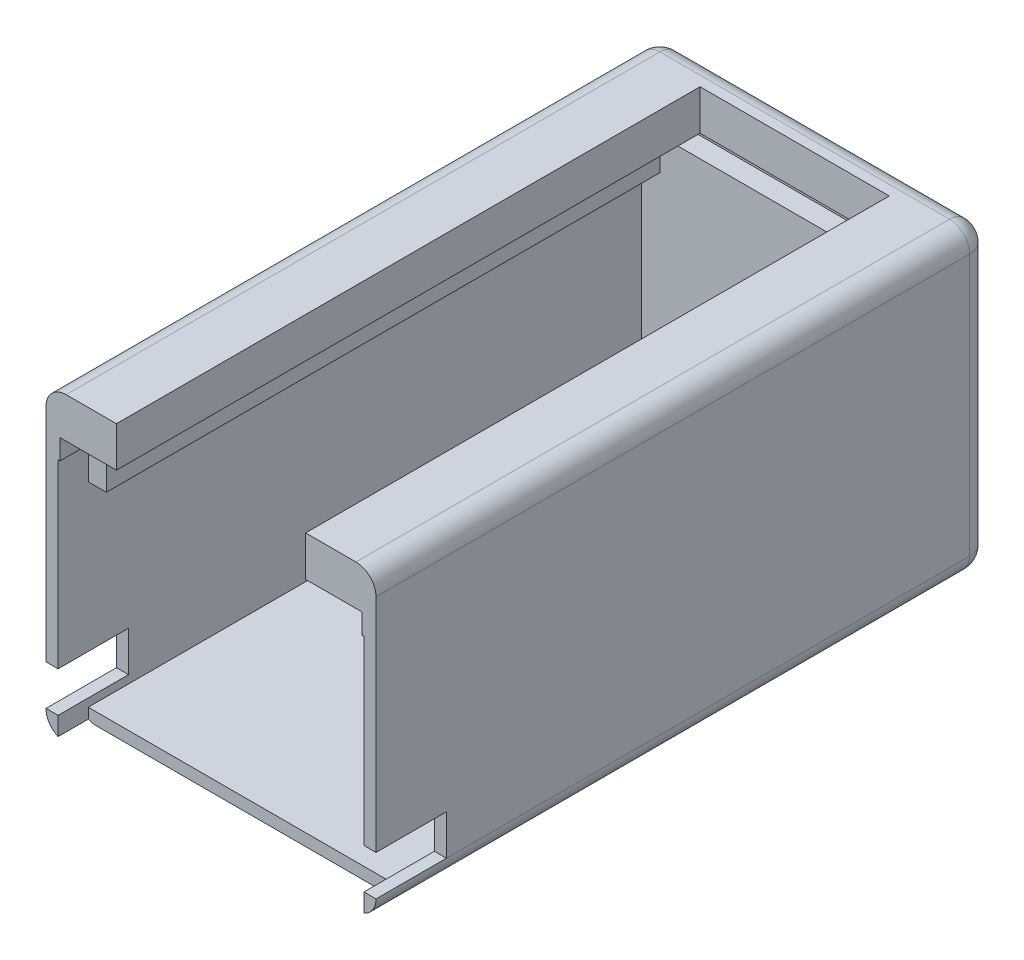
from build123d import *

# Parameters (mm, degrees)
CROQUIS1_W              = 82
CROQUIS1_H              = 155
SALIENTE_EXTRUIR1_DEPTH = 5
CROQUIS1_3_W            = 82
CROQUIS1_3_H            = 155
CROQUIS1_3_W_2          = 67
CROQUIS1_3_H_2          = 142.5
SALIENTE_EXTRUIR2_DEPTH = 80
CROQUIS2_W              = 20
CROQUIS2_H              = 10
CORTAR_EXTRUIR1_DEPTH   = 120
CROQUIS4_W              = 75
CROQUIS4_H              = 5.5
CORTAR_EXTRUIR2_DEPTH   = 152.5
CROQUIS5_W              = 67
CROQUIS5_H              = 5
CORTAR_EXTRUIR4_DEPTH   = 140
CROQUIS6_W              = 147.5
CROQUIS6_H              = 15
SALIENTE_EXTRUIR3_DEPTH = 10
CORTAR_EXTRUIR5_DEPTH   = 147.5
CROQUIS7_3_W            = 82
CROQUIS7_3_H            = 5
CORTAR_EXTRUIR6_DEPTH   = 167.5
CROQUIS8_W              = 76
CROQUIS8_H              = 10
CORTAR_EXTRUIR7_DEPTH   = 60
CROQUIS9_W              = 82
CROQUIS9_H              = 2.5
CORTAR_EXTRUIR8_DEPTH   = 300
REDONDEO1_R             = 5


with BuildPart() as part:
    # Croquis1 → Saliente-Extruir1 (new body)
    with BuildSketch(Plane(origin=(0, 0, 0), x_dir=(1, 0, 0), z_dir=(0, 1, 0))):
        with Locations((0, 7.5)):
            Rectangle(CROQUIS1_W, CROQUIS1_H)
    extrude(amount=SALIENTE_EXTRUIR1_DEPTH)

    # Croquis1_3 → Saliente-Extruir2 (add)
    with BuildSketch(Plane(origin=(0, 0, 0), x_dir=(1, 0, 0), z_dir=(0, 1, 0))):
        with Locations((0, 7.5)):
            Rectangle(CROQUIS1_3_W, CROQUIS1_3_H)
        with Locations((0, 6.25)):
            Rectangle(CROQUIS1_3_W_2, CROQUIS1_3_H_2, mode=Mode.SUBTRACT)
    extrude(amount=SALIENTE_EXTRUIR2_DEPTH)

    # Croquis2 → Cortar-Extruir1 (cut)
    with BuildSketch(Plane.ZY.offset(41)):
        with Locations((60, 10)):
            Rectangle(CROQUIS2_W, CROQUIS2_H)
    extrude(amount=-CORTAR_EXTRUIR1_DEPTH, mode=Mode.SUBTRACT)

    # Croquis4 → Cortar-Extruir2 (cut)
    with BuildSketch(Plane.XY.offset(70)):
        with Locations((0, 62.25)):
            Rectangle(CROQUIS4_W, CROQUIS4_H)
    extrude(amount=-CORTAR_EXTRUIR2_DEPTH, mode=Mode.SUBTRACT)

    # Croquis5 → Cortar-Extruir4 (cut)
    with BuildSketch(Plane(origin=(0, 80, 0), x_dir=(1, 0, 0), z_dir=(0, 1, 0))):
        with Locations((0, -67.5)):
            Rectangle(CROQUIS5_W, CROQUIS5_H)
    extrude(amount=-CORTAR_EXTRUIR4_DEPTH, mode=Mode.SUBTRACT)

    # Croquis6 → Saliente-Extruir3 (add)
    with BuildSketch(Plane(origin=(-33.5, 0, 0), x_dir=(0, 0, -1), z_dir=(1, 0, 0))):
        with Locations((3.75, 72.5)):
            Rectangle(CROQUIS6_W, CROQUIS6_H)
    saliente_extruir3 = extrude(amount=SALIENTE_EXTRUIR3_DEPTH)

    # Simetría1: Saliente-Extruir3 across plane
    add(saliente_extruir3.mirror(Plane(origin=(0, 0, 0), x_dir=(0, 0, 1), z_dir=(1, 0, 0))))

    # Croquis7 → Cortar-Extruir5 (cut)
    with BuildSketch(Plane.XY.offset(70)):
        Polygon((38, 51.5), (-33.5, 51.5), (-38, 51.5), (-38, 3), (38, 3), align=None)
    extrude(amount=-CORTAR_EXTRUIR5_DEPTH, mode=Mode.SUBTRACT)

    # Croquis7_3 → Cortar-Extruir6 (cut)
    with BuildSketch(Plane.XY.offset(70)):
        with Locations((0, 77.5)):
            Rectangle(CROQUIS7_3_W, CROQUIS7_3_H)
    extrude(amount=-CORTAR_EXTRUIR6_DEPTH, mode=Mode.SUBTRACT)

    # Croquis8 → Cortar-Extruir7 (cut)
    with BuildSketch(Plane(origin=(0, 0, 0), x_dir=(-1, 0, 0), z_dir=(0, -1, 0))):
        with Locations((0, -65)):
            Rectangle(CROQUIS8_W, CROQUIS8_H)
    extrude(amount=-CORTAR_EXTRUIR7_DEPTH, mode=Mode.SUBTRACT)

    # Croquis9 → Cortar-Extruir8 (cut)
    with BuildSketch(Plane.XZ):
        with Locations((0, 68.75)):
            Rectangle(CROQUIS9_W, CROQUIS9_H)
    extrude(amount=-CORTAR_EXTRUIR8_DEPTH, mode=Mode.SUBTRACT)

    # Redondeo1
    redondeo1_edges = [part.edges().sort_by_distance(p)[0] for p in [
        (0, 75, -85),
        (41, 75, -8.75),
        (-41, 75, -8.75),
        (-41, 0, -8.75),
        (41, 0, -8.75),
        (0, 0, -85),
        (-41, 37.5, -85),
        (41, 37.5, -85),
    ]]
    fillet(redondeo1_edges, radius=REDONDEO1_R)


solid = part.part
